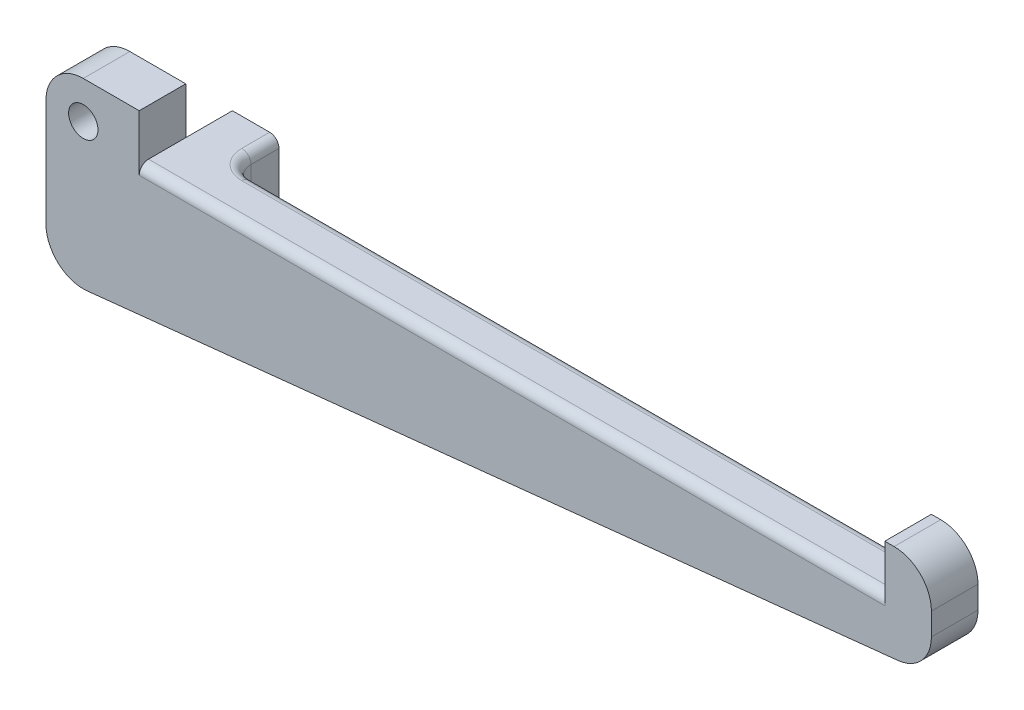
from build123d import *

# Parameters (mm, degrees)
BOSS_EXTRUDE1_DEPTH = 6.35
SKETCH2_W           = 6.35
SKETCH2_H           = 12.7
BOSS_EXTRUDE2_DEPTH = 6.35
FILLET1_R           = 2.54
FILLET2_R           = 1.27
SKETCH3_R           = 2
CUT_EXTRUDE1_DEPTH  = 6.35


with BuildPart() as part:
    # Sketch1 → Boss-Extrude1 (new body)
    with BuildSketch(Plane.XY):
        with BuildLine():
            Line((0, 0), (0, 7.62))
            ThreePointArc((0, 7.62), (1.487897552, 11.212102448), (5.08, 12.7))
            Line((5.08, 12.7), (12.7, 12.7))
            Line((12.7, 12.7), (12.7, 6.35))
            Line((12.7, 6.35), (114.3, 6.35))
            Line((114.3, 6.35), (114.3, 12.7))
            Line((114.3, 12.7), (115.57, 12.7))
            ThreePointArc((115.57, 12.7), (119.162102448, 11.212102448), (120.65, 7.62))
            Line((120.65, 7.62), (120.65, 4.57332967))
            ThreePointArc((120.65, 4.57332967), (119.34544285, 1.174442898), (116.101798705, -0.478758031))
            Line((116.101798705, -0.478758031), (5.611798705, -12.109284347))
            ThreePointArc((5.611798705, -12.109284347), (1.681113228, -10.832639496), (0, -7.057196646))
            Line((0, -7.057196646), (0, 0))
        make_face()
    extrude(amount=BOSS_EXTRUDE1_DEPTH)

    # Sketch2 → Boss-Extrude2 (add)
    with BuildSketch(Plane(origin=(0, 0, 0), x_dir=(-1, 0, 0), z_dir=(0, 0, -1))):
        with Locations((-15.875, 0)):
            Rectangle(SKETCH2_W, SKETCH2_H)
    extrude(amount=BOSS_EXTRUDE2_DEPTH)

    # Fillet1
    fillet1_edges = [part.edges().sort_by_distance(p)[0] for p in [
        (19.05, 0, 0),
    ]]
    fillet(fillet1_edges, radius=FILLET1_R)

    # Fillet2
    fillet2_edges = [part.edges().sort_by_distance(p)[0] for p in [
        (67.945, 6.35, 0),
        (63.5, 6.35, 6.35),
        (19.05, 6.35, -4.445),
        (19.793948776, 6.35, -0.743948776),
    ]]
    fillet(fillet2_edges, radius=FILLET2_R)

    # Sketch3 → Cut-Extrude1 (cut)
    with BuildSketch(Plane(origin=(0, 0, 0), x_dir=(-1, 0, 0), z_dir=(0, 0, -1))):
        with Locations((-5.08, 7.62)):
            Circle(SKETCH3_R)
    extrude(amount=-CUT_EXTRUDE1_DEPTH, mode=Mode.SUBTRACT)


solid = part.part
